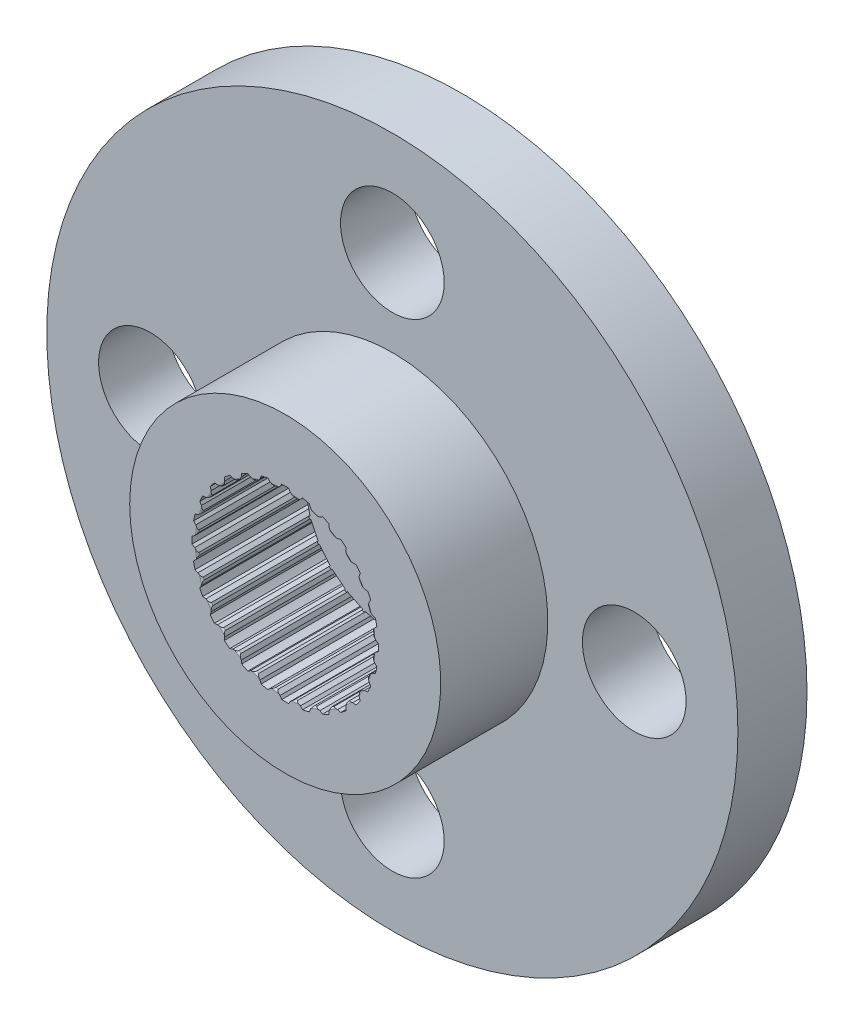
from build123d import *

# Parameters (mm, degrees)
CROQUIS1_R              = 10
CROQUIS1_R_2            = 1.5
SALIENTE_EXTRUIR1_DEPTH = 2
CROQUIS3_R              = 4.5
CROQUIS3_R_2            = 2.55
SALIENTE_EXTRUIR3_DEPTH = 3.1
CORTAR_EXTRUIR2_DEPTH   = 3.4
REDONDEO1_R             = 0.05
MATRIZC1_COUNT          = 28


with BuildPart() as part:
    # Croquis1 → Saliente-Extruir1 (new body)
    with BuildSketch(Plane.XY):
        Circle(CROQUIS1_R)
        with Locations((-7, 0)):
            Circle(CROQUIS1_R_2, mode=Mode.SUBTRACT)
        with Locations((0, 7)):
            Circle(CROQUIS1_R_2, mode=Mode.SUBTRACT)
        with Locations((0, -7)):
            Circle(CROQUIS1_R_2, mode=Mode.SUBTRACT)
        with Locations((7, 0)):
            Circle(CROQUIS1_R_2, mode=Mode.SUBTRACT)
        Circle(CROQUIS1_R_2, mode=Mode.SUBTRACT)
    extrude(amount=SALIENTE_EXTRUIR1_DEPTH)

    # Croquis3 → Saliente-Extruir3 (add)
    with BuildSketch(Plane.XY.offset(2)):
        with Locations(Location((0, 0, 0), (0, 0, 180))):
            Circle(CROQUIS3_R)
        with Locations(Location((0, 0, 0), (0, 0, 180))):
            Circle(CROQUIS3_R_2, mode=Mode.SUBTRACT)
    extrude(amount=SALIENTE_EXTRUIR3_DEPTH)

    # Croquis4 → Cortar-Extruir2 (cut)
    with BuildSketch(Plane.XY.offset(5.1)):
        with BuildLine():
            Line((0, 2.7), (0, 2.55))
            ThreePointArc((0, 2.55), (0.125150818, 2.546927025), (0.25, 2.537715508))
            Line((0.25, 2.537715508), (0.15, 2.62))
            Line((0.15, 2.62), (0.1, 2.698147513))
            ThreePointArc((0.1, 2.698147513), (0.050008579, 2.699536838), (0, 2.7))
        make_face()
        with BuildLine():
            ThreePointArc((-0.25, 2.537715508), (-0.125150818, 2.546927025), (0, 2.55))
            Line((0, 2.55), (0, 2.7))
            ThreePointArc((0, 2.7), (-0.050008579, 2.699536838), (-0.1, 2.698147513))
            Line((-0.1, 2.698147513), (-0.15, 2.62))
            Line((-0.15, 2.62), (-0.25, 2.537715508))
        make_face()
        with BuildLine():
            Line((0, 2.55), (0, 2.497452058))
            Line((0, 2.497452058), (0.246033494, 2.497452058))
            Line((0.246033494, 2.497452058), (0.25, 2.537715508))
            ThreePointArc((0.25, 2.537715508), (0.125150818, 2.546927025), (0, 2.55))
        make_face()
        with BuildLine():
            Line((-0.246033494, 2.497452058), (0, 2.497452058))
            Line((0, 2.497452058), (0, 2.55))
            ThreePointArc((0, 2.55), (-0.125150818, 2.546927025), (-0.25, 2.537715508))
            Line((-0.25, 2.537715508), (-0.246033494, 2.497452058))
        make_face()
    cortar_extruir2 = extrude(amount=-CORTAR_EXTRUIR2_DEPTH, mode=Mode.SUBTRACT)

    # Redondeo1
    redondeo1_edges = [part.edges().sort_by_distance(p)[0] for p in [
        (0, -2.55, 5.1),
    ]]
    fillet(redondeo1_edges, radius=REDONDEO1_R)

    # MatrizC1: Cortar-Extruir2 ×28 about axis
    matrizc1_axis = Axis((0, 0, 0), (0, 0, 1))
    for i in range(1, MATRIZC1_COUNT):
        add(cortar_extruir2.rotate(matrizc1_axis, i * 360 / MATRIZC1_COUNT), mode=Mode.SUBTRACT)


solid = part.part
